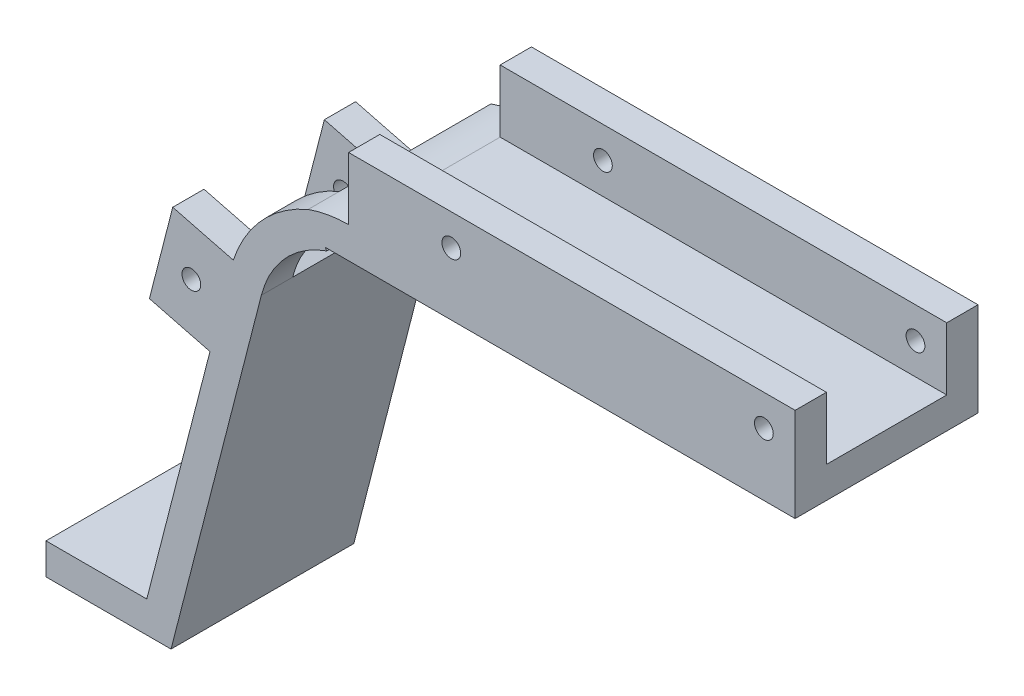
from build123d import *

# Parameters (mm, degrees)
SKETCH1_W               = 120
SKETCH1_H               = 100
BOSS_EXTRUDE1_DEPTH     = 5
SKETCH2_R               = 2.5
CUT_EXTRUDE1_DEPTH      = 6
CUT_EXTRUDE3_DEPTH      = 10
BOSS_EXTRUDE3_DEPTH     = 29.25
SKETCH8_W               = 20
SKETCH8_H               = 5
BOSS_EXTRUDE4_DEPTH     = 34.25
BOSS_EXTRUDE5_DEPTH     = 5
SKETCH11_W              = 5
SKETCH11_H              = 73
CUT_EXTRUDE6_DEPTH      = 1
CUT_EXTRUDE6_DEPTH_BACK = 120.837603572
SKETCH12_R              = 1.5
CUT_EXTRUDE7_DEPTH      = 69
CUT_EXTRUDE7_DEPTH_BACK = 6
SKETCH13_W              = 71.438611392
SKETCH13_H              = 5
BOSS_EXTRUDE6_DEPTH     = 10
SKETCH14_R              = 1.5
CUT_EXTRUDE8_DEPTH      = 30.25
SKETCH15_W              = 5
SKETCH15_H              = 14.999673458
SKETCH15_H_2            = 15
BOSS_EXTRUDE7_DEPTH     = 10
SKETCH17_R              = 1.5
CUT_EXTRUDE9_DEPTH      = 30.25


with BuildPart() as part:
    # Sketch1 → Boss-Extrude1 (new body)
    with BuildSketch(Plane.XY):
        with Locations((60, 50)):
            Rectangle(SKETCH1_W, SKETCH1_H)
    extrude(amount=BOSS_EXTRUDE1_DEPTH)

    # Sketch2 → Cut-Extrude1 (cut, through all)
    with BuildSketch(Plane.XY.offset(5)):
        with Locations((48.561388608, 53.909722104)):
            Circle(SKETCH2_R)
        with BuildLine():
            ThreePointArc((83.119368898, 4.555811435), (92.903152754, 13.119153924), (100.621925378, 23.582127225))
            ThreePointArc((100.621925378, 23.582127225), (96.02283809, 41.016960064), (78.588005251, 36.417872775))
            ThreePointArc((78.588005251, 36.417872775), (74.136099049, 30.383211826), (68.493169771, 25.444188565))
            ThreePointArc((68.493169771, 25.444188565), (65.36208077, 7.686900437), (83.119368898, 4.555811435))
        make_face()
    extrude(amount=-CUT_EXTRUDE1_DEPTH, mode=Mode.SUBTRACT)

    # Sketch5 → Cut-Extrude3 (cut)
    with BuildSketch(Plane.XY.offset(5)):
        with BuildLine():
            Line((120, 73), (48.561388608, 73))
            ThreePointArc((48.561388608, 73), (36.862057433, 68.994958603), (30.071644393, 58.660308282))
            Line((30.071644393, 58.660308282), (15, 0))
            Line((15, 0), (0, 0))
            Line((0, 0), (0, 100))
            Line((0, 100), (120, 100))
            Line((120, 100), (120, 73))
        make_face()
    extrude(amount=-CUT_EXTRUDE3_DEPTH, mode=Mode.SUBTRACT)

    # Sketch7 → Boss-Extrude3 (add)
    with BuildSketch(Plane(origin=(0, 0, 0), x_dir=(-1, 0, 0), z_dir=(0, 0, -1))):
        Polygon((-15, 0), (-30.123935814, 58.863831587), (-34.614250087, 56.248022366), (-20.162396428, 0), align=None)
        with BuildLine():
            Line((-120, 73), (-48.561388608, 73))
            ThreePointArc((-48.561388608, 73), (-45.276527497, 72.715263777), (-42.089655421, 71.869548932))
            Line((-42.089655421, 71.869548932), (-44.799142753, 68))
            Line((-44.799142753, 68), (-120, 68))
            Line((-120, 68), (-120, 73))
        make_face()
    extrude(amount=BOSS_EXTRUDE3_DEPTH)

    # Sketch8 → Boss-Extrude4 (add, through all)
    with BuildSketch(Plane(origin=(0, 0, -29.25), x_dir=(-1, 0, 0), z_dir=(0, 0, -1))):
        with Locations((-10.162396428, 2.5)):
            Rectangle(SKETCH8_W, SKETCH8_H)
    extrude(amount=-BOSS_EXTRUDE4_DEPTH)

    # Sketch10 → Boss-Extrude5 (add)
    with BuildSketch(Plane(origin=(0, 0, 0), x_dir=(-1, 0, 0), z_dir=(0, 0, -1))):
        with BuildLine():
            Line((-45.069655622, 67.613667586), (-42.089655421, 71.869548932))
            ThreePointArc((-42.089655421, 71.869548932), (-34.697505551, 66.663289264), (-30.124971237, 58.863228407))
            Line((-30.124971237, 58.863228407), (-34.614250087, 56.248022366))
            ThreePointArc((-34.614250087, 56.248022366), (-38.409874026, 63.248233001), (-45.069655622, 67.613667586))
        make_face()
    extrude(amount=BOSS_EXTRUDE5_DEPTH)

    # Sketch11 → Cut-Extrude6 (cut, two sides)
    with BuildSketch(Plane(origin=(120, 0, 0), x_dir=(0, 0, -1), z_dir=(1, 0, 0))) as cut_extrude6_sk:
        with Locations((-2.5, 36.5)):
            Rectangle(SKETCH11_W, SKETCH11_H)
    extrude(amount=CUT_EXTRUDE6_DEPTH, mode=Mode.SUBTRACT)
    extrude(cut_extrude6_sk.sketch, amount=-CUT_EXTRUDE6_DEPTH_BACK, mode=Mode.SUBTRACT)

    # Sketch12 → Cut-Extrude7 (cut, two sides)
    with BuildSketch(Plane(origin=(0, 5, 0), x_dir=(1, 0, 0), z_dir=(0, 1, 0))) as cut_extrude7_sk:
        with Locations((7.662396428, 14.625)):
            Circle(SKETCH12_R)
    extrude(amount=CUT_EXTRUDE7_DEPTH, mode=Mode.SUBTRACT)
    extrude(cut_extrude7_sk.sketch, amount=-CUT_EXTRUDE7_DEPTH_BACK, mode=Mode.SUBTRACT)

    # Sketch13 → Boss-Extrude6 (add)
    with BuildSketch(Plane(origin=(0, 73, 0), x_dir=(1, 0, 0), z_dir=(0, 1, 0))):
        with Locations((84.280694304, 2.5)):
            Rectangle(SKETCH13_W, SKETCH13_H)
        with Locations((84.280694304, 26.75)):
            Rectangle(SKETCH13_W, SKETCH13_H)
    extrude(amount=BOSS_EXTRUDE6_DEPTH)

    # Sketch14 → Cut-Extrude8 (cut, through all)
    with BuildSketch(Plane.XY):
        with Locations((65, 78)):
            Circle(SKETCH14_R)
        with Locations((115, 78)):
            Circle(SKETCH14_R)
    extrude(amount=-CUT_EXTRUDE8_DEPTH, mode=Mode.SUBTRACT)

    # Sketch15 → Boss-Extrude7 (add)
    with BuildSketch(Plane(origin=(14.07111669, -3.615304337, 0), x_dir=(0, 0, 1), z_dir=(-0.968542434, 0.248848456, 0))):
        with Locations((-2.5, 57.008250348)):
            Rectangle(SKETCH15_W, SKETCH15_H)
        with Locations((-26.75, 57.008413619)):
            Rectangle(SKETCH15_W, SKETCH15_H_2)
    extrude(amount=BOSS_EXTRUDE7_DEPTH)

    # Sketch17 → Cut-Extrude9 (cut, through all)
    with BuildSketch(Plane.XY):
        with Locations((23.414860226, 52.844005614)):
            Circle(SKETCH17_R)
    extrude(amount=-CUT_EXTRUDE9_DEPTH, mode=Mode.SUBTRACT)


solid = part.part
